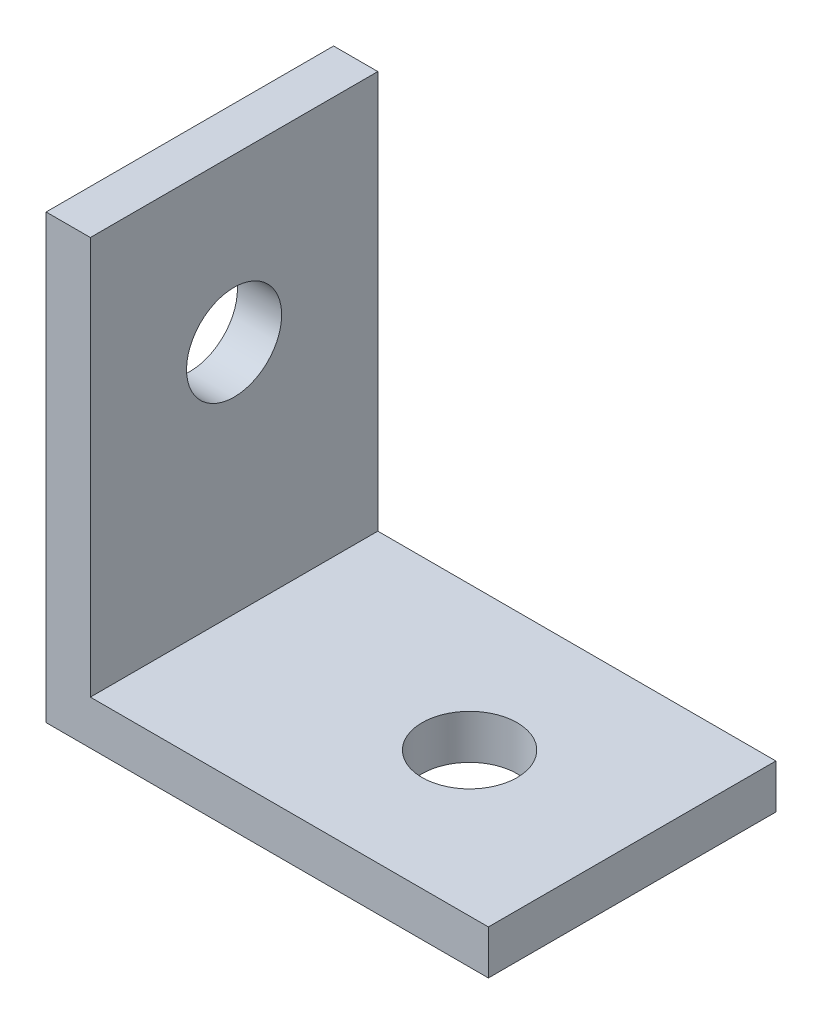
from build123d import *

# Parameters (mm, degrees)
BOSS_EXTRUDE1_DEPTH = 13
SKETCH2_R           = 2.15
CUT_EXTRUDE1_DEPTH  = 21
SKETCH3_R           = 2.15
CUT_EXTRUDE2_DEPTH  = 21


with BuildPart() as part:
    # Sketch1 → Boss-Extrude1 (new body)
    with BuildSketch(Plane.XY):
        Polygon((0, 20), (0, 0), (20, 0), (20, 2), (2, 2), (2, 20), align=None)
    extrude(amount=BOSS_EXTRUDE1_DEPTH)

    # Sketch2 → Cut-Extrude1 (cut, through all)
    with BuildSketch(Plane.ZY):
        with Locations((6.5, 12.65)):
            Circle(SKETCH2_R)
    extrude(amount=-CUT_EXTRUDE1_DEPTH, mode=Mode.SUBTRACT)

    # Sketch3 → Cut-Extrude2 (cut, through all)
    with BuildSketch(Plane.XZ):
        with Locations((12.65, 6.5)):
            Circle(SKETCH3_R)
    extrude(amount=-CUT_EXTRUDE2_DEPTH, mode=Mode.SUBTRACT)


solid = part.part
